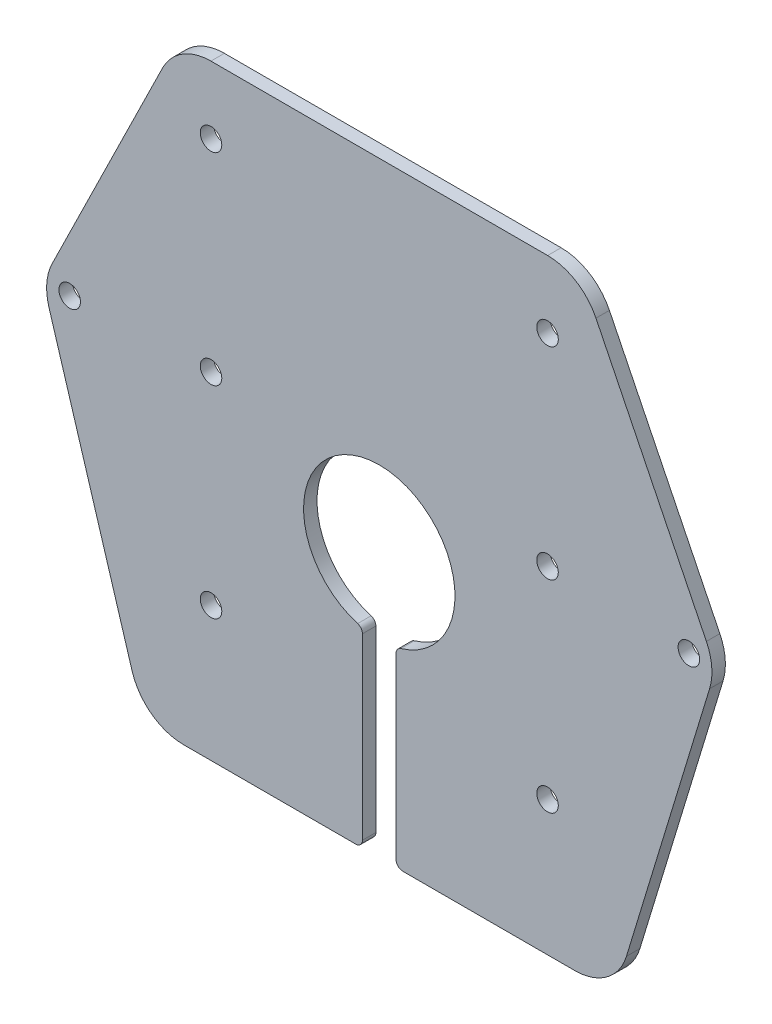
from build123d import *

# Parameters (mm, degrees)
SKETCH_1_R          = 1.6
EXTRUDE_1_DEPTH     = 2
FILLET_1_R          = 8
CUT_EXTRUDE_1_DEPTH = 10
FILLET_2_R          = 1


with BuildPart() as part:
    # 草图1 → 凸台-拉伸1 (new body)
    with BuildSketch(Plane.XY):
        Polygon((-30, 0), (30, 0), (50, -40.7), (35, -90), (-35, -90), (-50, -40.7), align=None)
        with Locations((-25, -10)):
            Circle(SKETCH_1_R, mode=Mode.SUBTRACT)
        with Locations((-46, -40.7)):
            Circle(SKETCH_1_R, mode=Mode.SUBTRACT)
        with Locations((25, -10)):
            Circle(SKETCH_1_R, mode=Mode.SUBTRACT)
        with Locations((46, -40.7)):
            Circle(SKETCH_1_R, mode=Mode.SUBTRACT)
        with Locations((-25, -40)):
            Circle(SKETCH_1_R, mode=Mode.SUBTRACT)
        with Locations((25, -40)):
            Circle(SKETCH_1_R, mode=Mode.SUBTRACT)
        with Locations((-25, -70)):
            Circle(SKETCH_1_R, mode=Mode.SUBTRACT)
        with Locations((25, -70)):
            Circle(SKETCH_1_R, mode=Mode.SUBTRACT)
    extrude(amount=EXTRUDE_1_DEPTH)

    # 圆角1
    fillet_1_edges = [part.edges().sort_by_distance(p)[0] for p in [
        (50, -40.7, 1),
        (35, -90, 1),
        (-35, -90, 1),
        (-50, -40.7, 1),
        (-30, 0, 1),
        (30, 0, 1),
    ]]
    fillet(fillet_1_edges, radius=FILLET_1_R)

    # 草图2 → 切除-拉伸1 (cut)
    with BuildSketch(Plane.XY.offset(2)):
        with BuildLine():
            Line((-2.5, -61.668705484), (-2.5, -90))
            Line((-2.5, -90), (2.5, -90))
            Line((2.5, -90), (2.5, -61.668705484))
            ThreePointArc((2.5, -61.668705484), (0, -39.45), (-2.5, -61.668705484))
        make_face()
    extrude(amount=-CUT_EXTRUDE_1_DEPTH, mode=Mode.SUBTRACT)

    # 圆角2
    fillet_2_edges = [part.edges().sort_by_distance(p)[0] for p in [
        (2.5, -61.668705484, 1),
        (-2.5, -61.668705484, 1),
        (-2.5, -90, 1),
        (2.5, -90, 1),
    ]]
    fillet(fillet_2_edges, radius=FILLET_2_R)


solid = part.part
